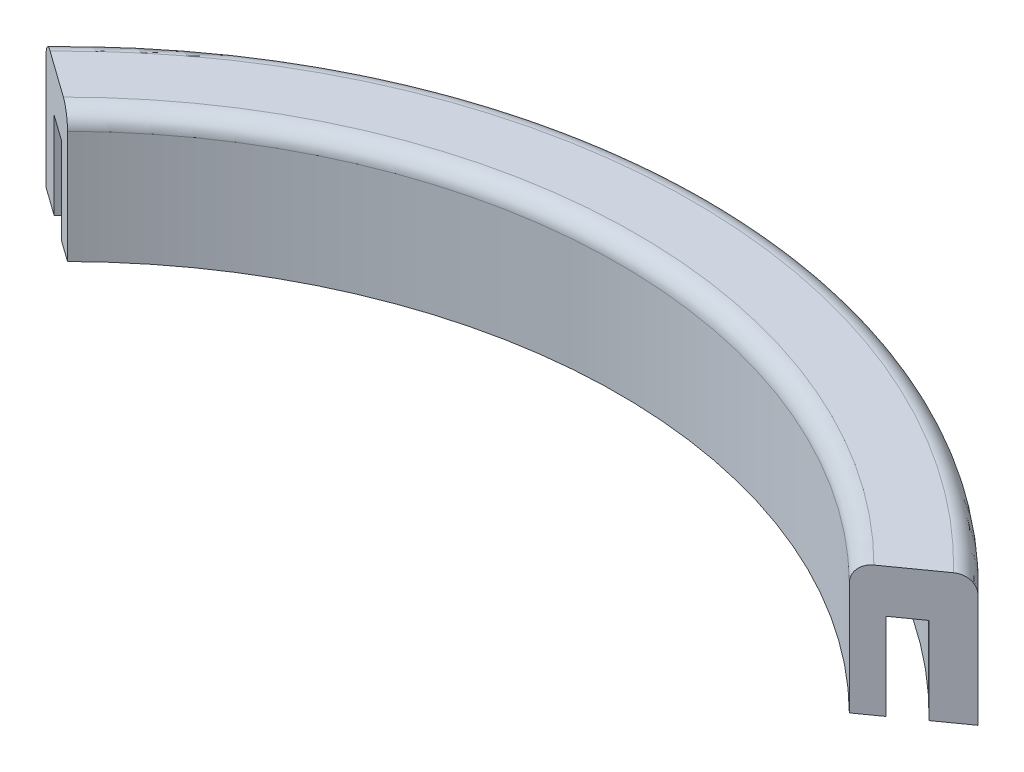
from build123d import *

# Parameters (mm, degrees)
BOSS_EXTRUDE1_DEPTH = 19.05
CUT_EXTRUDE1_DEPTH  = 12.7
FILLET1_R           = 2.54


with BuildPart() as part:
    # Sketch1 → Boss-Extrude1 (new body)
    with BuildSketch(Plane(origin=(0, 0, 0), x_dir=(1, 0, 0), z_dir=(0, 1, 0))):
        with BuildLine():
            Line((57.234735331, 57.711554056), (68.22559355, 65.553540024))
            ThreePointArc((68.22559355, 65.553540024), (0, 94.615), (-68.22559355, 65.553540024))
            Line((-68.22559355, 65.553540024), (-57.234735331, 57.711554056))
            ThreePointArc((-57.234735331, 57.711554056), (0, 81.28), (57.234735331, 57.711554056))
        make_face()
    extrude(amount=BOSS_EXTRUDE1_DEPTH)

    # Sketch3 → Cut-Extrude1 (cut)
    with BuildSketch(Plane.XZ):
        with BuildLine():
            Line((-60.379405736, -59.955278859), (-64.043453365, -62.569579718))
            ThreePointArc((-64.043453365, -62.569579718), (0, -89.535), (64.043453365, -62.569579718))
            Line((64.043453365, -62.569579718), (60.379405736, -59.955278859))
            ThreePointArc((60.379405736, -59.955278859), (0, -85.09), (-60.379405736, -59.955278859))
        make_face()
    extrude(amount=-CUT_EXTRUDE1_DEPTH, mode=Mode.SUBTRACT)

    # Fillet1
    fillet1_edges = [part.edges().sort_by_distance(p)[0] for p in [
        (0, 19.05, -81.28),
        (0, 19.05, -94.615),
    ]]
    fillet(fillet1_edges, radius=FILLET1_R)


solid = part.part
